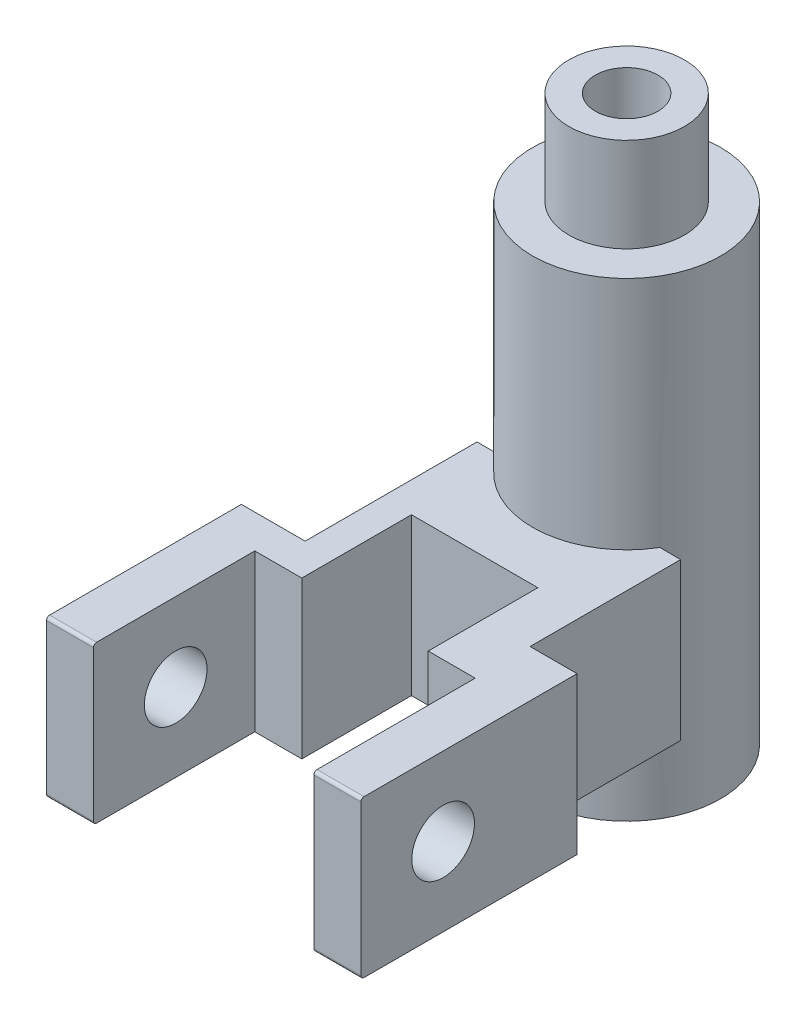
from build123d import *

# Parameters (mm, degrees)
BOSS_EXTRUDE1_DEPTH = 50
SKETCH2_R           = 30
BOSS_EXTRUDE2_DEPTH = 75
SKETCH3_R           = 18.435978865
BOSS_EXTRUDE3_DEPTH = 30
SKETCH4_R           = 10
CUT_EXTRUDE1_DEPTH  = 220
FILLET1_R           = 1
SKETCH6_R           = 10
CUT_EXTRUDE3_DEPTH  = 110


with BuildPart() as part:
    # Sketch1 → Boss-Extrude1 (new body)
    with BuildSketch(Plane(origin=(0, 0, 0), x_dir=(1, 0, 0), z_dir=(0, 1, 0))):
        Polygon((-42.485875706, 40.677966102), (-42.485875706, -8.276836158), (-62.824858757, -8.276836158), (-62.824858757, -39.011299435), (-62.824858757, -70.484281789), (-47.824858757, -70.484281789), (-47.824858757, -19.011299435), (-32.824858757, -19.011299435), (-32.824858757, 15.988700565), (7.514124294, 15.988700565), (7.514124294, -19.011299435), (22.514124294, -19.011299435), (22.514124294, -70.484281789), (37.514124294, -70.484281789), (37.514124294, -39.011299435), (37.514124294, -1.511299435), (22.514124294, -1.511299435), (22.514124294, 46.553672316), (-42.485875706, 46.553672316), align=None)
    extrude(amount=BOSS_EXTRUDE1_DEPTH)

    # Sketch2 → Boss-Extrude2 (add, symmetric)
    with BuildSketch(Plane(origin=(0, 50, 0), x_dir=(1, 0, 0), z_dir=(0, 1, 0))):
        with Locations((-9.985875706, 61.810417825)):
            Circle(SKETCH2_R)
    extrude(amount=BOSS_EXTRUDE2_DEPTH, both=True)

    # Sketch3 → Boss-Extrude3 (add)
    with BuildSketch(Plane(origin=(0, 125, 0), x_dir=(1, 0, 0), z_dir=(0, 1, 0))):
        with Locations((-9.985875706, 61.810417825)):
            Circle(SKETCH3_R)
    extrude(amount=BOSS_EXTRUDE3_DEPTH)

    # Sketch4 → Cut-Extrude1 (cut)
    with BuildSketch(Plane(origin=(0, 155, 0), x_dir=(1, 0, 0), z_dir=(0, 1, 0))):
        with Locations((-9.985875706, 61.810417825)):
            Circle(SKETCH4_R)
    extrude(amount=-CUT_EXTRUDE1_DEPTH, mode=Mode.SUBTRACT)

    # Fillet1
    fillet1_edges = [part.edges().sort_by_distance(p)[0] for p in [
        (30.014124294, 0, 70.484281789),
        (-55.324858757, 0, 70.484281789),
        (-55.324858757, 50, 70.484281789),
        (30.014124294, 50, 70.484281789),
    ]]
    fillet(fillet1_edges, radius=FILLET1_R)

    # Sketch6 → Cut-Extrude3 (cut, symmetric)
    with BuildSketch(Plane(origin=(-47.824858757, 0, 0), x_dir=(0, 0, -1), z_dir=(1, 0, 0))):
        with Locations((-44.247790612, 25)):
            Circle(SKETCH6_R)
    extrude(amount=CUT_EXTRUDE3_DEPTH, both=True, mode=Mode.SUBTRACT)


solid = part.part
